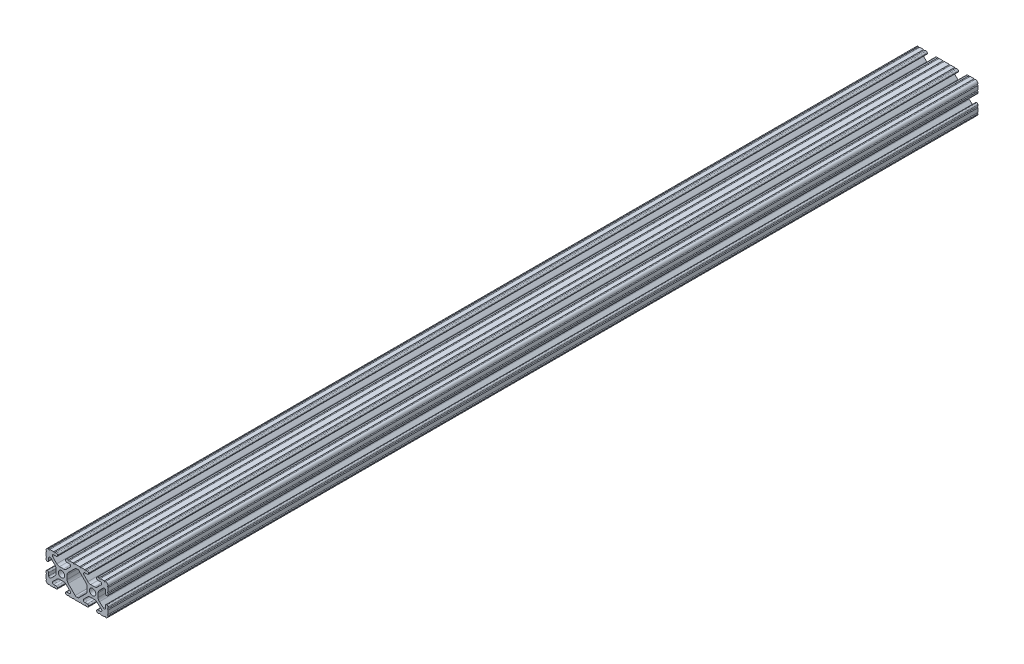
from build123d import *

# Parameters (mm, degrees)
SKETCH1_R           = 2.6035
BOSS_EXTRUDE1_DEPTH = 355.6


with BuildPart() as part:
    # Sketch1 → Boss-Extrude1 (new body, symmetric)
    with BuildSketch(Plane.XY):
        with BuildLine():
            Line((18.01710265, 12.7), (16.98745015, 12.7))
            ThreePointArc((16.98745015, 12.7), (16.245730386, 12.392769614), (15.9385, 11.65104985))
            Line((15.9385, 11.65104985), (15.9385, 11.53922))
            ThreePointArc((15.9385, 11.53922), (16.245750844, 10.797450844), (16.98752, 10.4902))
            Line((16.98752, 10.4902), (19.116384363, 10.4902))
            ThreePointArc((19.116384363, 10.4902), (20.052502933, 9.869096983), (19.844087081, 8.765172272))
            Line((19.844087081, 8.765172272), (16.618993479, 5.455112286))
            ThreePointArc((16.618993479, 5.455112286), (15.578994274, 4.745442459), (14.344932584, 4.4958))
            Line((14.344932584, 4.4958), (11.083317835, 4.4958))
            ThreePointArc((11.083317835, 4.4958), (9.854330953, 4.743306833), (8.816955189, 5.447238587))
            Line((8.816955189, 5.447238587), (5.564154119, 8.762652677))
            ThreePointArc((5.564154119, 8.762652677), (5.352591412, 9.867473037), (6.289393385, 10.4902))
            Line((6.289393385, 10.4902), (8.41248, 10.4902))
            ThreePointArc((8.41248, 10.4902), (9.154249156, 10.797450844), (9.4615, 11.53922))
            Line((9.4615, 11.53922), (9.4615, 11.65104985))
            ThreePointArc((9.4615, 11.65104985), (9.154269614, 12.392769614), (8.41254985, 12.7))
            Line((8.41254985, 12.7), (7.38288465, 12.7))
            ThreePointArc((7.38288465, 12.7), (6.87488465, 12.192), (6.36688465, 12.7))
            Line((6.36688465, 12.7), (3.14958095, 12.7))
            ThreePointArc((3.14958095, 12.7), (2.64158095, 12.192), (2.13358095, 12.7))
            Line((2.13358095, 12.7), (-2.13358095, 12.7))
            ThreePointArc((-2.13358095, 12.7), (-2.64158095, 12.192), (-3.14958095, 12.7))
            Line((-3.14958095, 12.7), (-6.36689735, 12.7))
            ThreePointArc((-6.36689735, 12.7), (-6.87489735, 12.192), (-7.38289735, 12.7))
            Line((-7.38289735, 12.7), (-8.41254985, 12.7))
            ThreePointArc((-8.41254985, 12.7), (-9.154269614, 12.392769614), (-9.4615, 11.65104985))
            Line((-9.4615, 11.65104985), (-9.4615, 11.53922))
            ThreePointArc((-9.4615, 11.53922), (-9.154249156, 10.797450844), (-8.41248, 10.4902))
            Line((-8.41248, 10.4902), (-6.283641037, 10.4902))
            ThreePointArc((-6.283641037, 10.4902), (-5.297291557, 9.829633109), (-5.532576693, 8.666071843))
            Line((-5.532576693, 8.666071843), (-8.809985098, 5.416263103))
            ThreePointArc((-8.809985098, 5.416263103), (-9.836720513, 4.734920264), (-11.045536121, 4.4958))
            Line((-11.045536121, 4.4958), (-14.354463879, 4.4958))
            ThreePointArc((-14.354463879, 4.4958), (-15.563279487, 4.734920264), (-16.590014902, 5.416263103))
            Line((-16.590014902, 5.416263103), (-19.867423307, 8.666071843))
            ThreePointArc((-19.867423307, 8.666071843), (-20.102708443, 9.829633109), (-19.116358963, 10.4902))
            Line((-19.116358963, 10.4902), (-16.98752, 10.4902))
            ThreePointArc((-16.98752, 10.4902), (-16.245750844, 10.797450844), (-15.9385, 11.53922))
            Line((-15.9385, 11.53922), (-15.9385, 11.65104985))
            ThreePointArc((-15.9385, 11.65104985), (-16.245730386, 12.392769614), (-16.98745015, 12.7))
            Line((-16.98745015, 12.7), (-18.01711535, 12.7))
            ThreePointArc((-18.01711535, 12.7), (-18.52511535, 12.192), (-19.03311535, 12.7))
            Line((-19.03311535, 12.7), (-22.2504, 12.7))
            ThreePointArc((-22.2504, 12.7), (-22.758323491, 12.192000006), (-23.266399977, 12.699846982))
            ThreePointArc((-23.266399977, 12.699846982), (-24.782522516, 12.082522516), (-25.399846982, 10.566399977))
            ThreePointArc((-25.399846982, 10.566399977), (-24.892000006, 10.058323491), (-25.4, 9.5504))
            Line((-25.4, 9.5504), (-25.4, 6.3330836))
            ThreePointArc((-25.4, 6.3330836), (-24.892, 5.8250836), (-25.4, 5.3170836))
            Line((-25.4, 5.3170836), (-25.4, 4.237520184))
            ThreePointArc((-25.4, 4.237520184), (-25.107393763, 3.531106237), (-24.400979816, 3.2385))
            Line((-24.400979816, 3.2385), (-24.23922, 3.2385))
            ThreePointArc((-24.23922, 3.2385), (-23.497450844, 3.545750844), (-23.1902, 4.28752))
            Line((-23.1902, 4.28752), (-23.1902, 6.334741132))
            ThreePointArc((-23.1902, 6.334741132), (-22.556026952, 7.286023527), (-21.434002553, 7.066535717))
            Line((-21.434002553, 7.066535717), (-18.147950853, 3.808156468))
            ThreePointArc((-18.147950853, 3.808156468), (-17.452759693, 2.774838327), (-17.208501877, 1.553619571))
            Line((-17.208501877, 1.553619571), (-17.208501877, -1.695179196))
            ThreePointArc((-17.208501877, -1.695179196), (-17.450738657, -2.911536421), (-18.140486065, -3.942289578))
            Line((-18.140486065, -3.942289578), (-21.431579576, -7.227386226))
            ThreePointArc((-21.431579576, -7.227386226), (-22.55444896, -7.449940594), (-23.1902, -6.498002195))
            Line((-23.1902, -6.498002195), (-23.1902, -4.28752))
            ThreePointArc((-23.1902, -4.28752), (-23.497450844, -3.545750844), (-24.23922, -3.2385))
            Line((-24.23922, -3.2385), (-24.35098, -3.2385))
            ThreePointArc((-24.35098, -3.2385), (-25.092749156, -3.545750844), (-25.4, -4.28752))
            Line((-25.4, -4.28752), (-25.4, -5.3171344))
            ThreePointArc((-25.4, -5.3171344), (-24.892, -5.8251344), (-25.4, -6.3331344))
            Line((-25.4, -6.3331344), (-25.4, -9.5504))
            ThreePointArc((-25.4, -9.5504), (-24.892000006, -10.058323491), (-25.399846982, -10.566399977))
            ThreePointArc((-25.399846982, -10.566399977), (-24.782522516, -12.082522516), (-23.266399977, -12.699846982))
            ThreePointArc((-23.266399977, -12.699846982), (-22.758323491, -12.192000006), (-22.2504, -12.7))
            Line((-22.2504, -12.7), (-19.03308995, -12.7))
            ThreePointArc((-19.03308995, -12.7), (-18.52508995, -12.192), (-18.01708995, -12.7))
            Line((-18.01708995, -12.7), (-16.9874692, -12.7))
            ThreePointArc((-16.9874692, -12.7), (-16.245700044, -12.392749156), (-15.9384492, -11.65098))
            Line((-15.9384492, -11.65098), (-15.9384492, -11.53922))
            ThreePointArc((-15.9384492, -11.53922), (-16.245700044, -10.797450844), (-16.9874692, -10.4902))
            Line((-16.9874692, -10.4902), (-19.116358963, -10.4902))
            ThreePointArc((-19.116358963, -10.4902), (-20.055197748, -9.862578342), (-19.834124023, -8.755124678))
            Line((-19.834124023, -8.755124678), (-16.49660751, -5.423689618))
            ThreePointArc((-16.49660751, -5.423689618), (-15.467274017, -4.736928798), (-14.253591699, -4.4958))
            Line((-14.253591699, -4.4958), (-11.146408301, -4.4958))
            ThreePointArc((-11.146408301, -4.4958), (-9.932725983, -4.736928798), (-8.90339249, -5.423689618))
            Line((-8.90339249, -5.423689618), (-5.565875977, -8.755124678))
            ThreePointArc((-5.565875977, -8.755124678), (-5.344802252, -9.862578342), (-6.283641037, -10.4902))
            Line((-6.283641037, -10.4902), (-8.4125308, -10.4902))
            ThreePointArc((-8.4125308, -10.4902), (-9.154299956, -10.797450844), (-9.4615508, -11.53922))
            Line((-9.4615508, -11.53922), (-9.4615508, -11.65098))
            ThreePointArc((-9.4615508, -11.65098), (-9.154299956, -12.392749156), (-8.4125308, -12.7))
            Line((-8.4125308, -12.7), (-7.38287195, -12.7))
            ThreePointArc((-7.38287195, -12.7), (-6.87487195, -12.192), (-6.36687195, -12.7))
            Line((-6.36687195, -12.7), (-3.14960635, -12.7))
            ThreePointArc((-3.14960635, -12.7), (-2.64160635, -12.192), (-2.13360635, -12.7))
            Line((-2.13360635, -12.7), (2.13360635, -12.7))
            ThreePointArc((2.13360635, -12.7), (2.64159365, -12.1920127), (3.14958095, -12.7))
            Line((3.14958095, -12.7), (6.36691005, -12.7))
            ThreePointArc((6.36691005, -12.7), (6.87491005, -12.192), (7.38291005, -12.7))
            Line((7.38291005, -12.7), (8.4125308, -12.7))
            ThreePointArc((8.4125308, -12.7), (9.154299956, -12.392749156), (9.4615508, -11.65098))
            Line((9.4615508, -11.65098), (9.4615508, -11.53922))
            ThreePointArc((9.4615508, -11.53922), (9.154299956, -10.797450844), (8.4125308, -10.4902))
            Line((8.4125308, -10.4902), (6.289393385, -10.4902))
            ThreePointArc((6.289393385, -10.4902), (5.231590322, -9.783049717), (5.480677245, -8.535265862))
            Line((5.480677245, -8.535265862), (8.597933595, -5.423689618))
            ThreePointArc((8.597933595, -5.423689618), (9.627267088, -4.736928798), (10.840949406, -4.4958))
            Line((10.840949406, -4.4958), (14.102564155, -4.4958))
            ThreePointArc((14.102564155, -4.4958), (15.215927525, -4.697410182), (16.187895372, -5.276636531))
            Line((16.187895372, -5.276636531), (19.868247549, -8.482246082))
            ThreePointArc((19.868247549, -8.482246082), (20.188435806, -9.746879864), (19.116384363, -10.4902))
            Line((19.116384363, -10.4902), (16.9874692, -10.4902))
            ThreePointArc((16.9874692, -10.4902), (16.245700044, -10.797450844), (15.9384492, -11.53922))
            Line((15.9384492, -11.53922), (15.9384492, -11.65098))
            ThreePointArc((15.9384492, -11.65098), (16.245700044, -12.392749156), (16.9874692, -12.7))
            Line((16.9874692, -12.7), (18.01710265, -12.7))
            ThreePointArc((18.01710265, -12.7), (18.52510265, -12.192), (19.03310265, -12.7))
            Line((19.03310265, -12.7), (22.2504, -12.7))
            ThreePointArc((22.2504, -12.7), (22.758323491, -12.192000006), (23.266399977, -12.699846982))
            ThreePointArc((23.266399977, -12.699846982), (24.782522516, -12.082522516), (25.399846982, -10.566399977))
            ThreePointArc((25.399846982, -10.566399977), (24.892000006, -10.058323492), (25.4, -9.550400001))
            Line((25.4, -9.550400001), (25.4, -6.333083592))
            ThreePointArc((25.4, -6.333083592), (24.892000001, -5.825083593), (25.4, -5.317083593))
            Line((25.4, -5.317083593), (25.4, -4.237520184))
            ThreePointArc((25.4, -4.237520184), (25.107393763, -3.531106237), (24.400979816, -3.2385))
            Line((24.400979816, -3.2385), (24.189220184, -3.2385))
            ThreePointArc((24.189220184, -3.2385), (23.482806237, -3.531106237), (23.1902, -4.237520184))
            Line((23.1902, -4.237520184), (23.1902, -6.155876159))
            ThreePointArc((23.1902, -6.155876159), (22.62232736, -7.038258539), (21.583974541, -6.886926384))
            Line((21.583974541, -6.886926384), (18.29817066, -4.024970844))
            ThreePointArc((18.29817066, -4.024970844), (17.493730985, -2.946044689), (17.208501877, -1.630807374))
            Line((17.208501877, -1.630807374), (17.208501877, 1.630807374))
            ThreePointArc((17.208501877, 1.630807374), (17.442348332, 2.82673414), (18.109440981, 3.846495088))
            Line((18.109440981, 3.846495088), (21.526346532, 7.353420386))
            ThreePointArc((21.526346532, 7.353420386), (22.585896263, 7.574939077), (23.1902, 6.676867167))
            Line((23.1902, 6.676867167), (23.1902, 4.237520184))
            ThreePointArc((23.1902, 4.237520184), (23.482806237, 3.531106237), (24.189220184, 3.2385))
            Line((24.189220184, 3.2385), (24.400979816, 3.2385))
            ThreePointArc((24.400979816, 3.2385), (25.107393763, 3.531106237), (25.4, 4.237520184))
            Line((25.4, 4.237520184), (25.4, 5.3170836))
            ThreePointArc((25.4, 5.3170836), (24.891949193, 5.825134407), (25.4, 6.333185215))
            Line((25.4, 6.333185215), (25.4, 9.550400015))
            ThreePointArc((25.4, 9.550400015), (24.892000013, 10.058323498), (25.399846982, 10.566399977))
            ThreePointArc((25.399846982, 10.566399977), (24.782522516, 12.082522516), (23.266399977, 12.699846982))
            ThreePointArc((23.266399977, 12.699846982), (22.758323491, 12.192000006), (22.2504, 12.7))
            Line((22.2504, 12.7), (19.03310265, 12.7))
            ThreePointArc((19.03310265, 12.7), (18.52510265, 12.192), (18.01710265, 12.7))
        make_face()
        with Locations((-12.7, 0)):
            Circle(SKETCH1_R, mode=Mode.SUBTRACT)
        with Locations((12.7, 0)):
            Circle(SKETCH1_R, mode=Mode.SUBTRACT)
        with BuildLine():
            Line((-7.259513935, -3.869413038), (-1.545748891, -9.572766749))
            ThreePointArc((-1.545748891, -9.572766749), (-1.035199478, -9.913400116), (-0.433213048, -10.033))
            Line((-0.433213048, -10.033), (0.433213048, -10.033))
            ThreePointArc((0.433213048, -10.033), (1.035199478, -9.913400116), (1.545748891, -9.572766749))
            Line((1.545748891, -9.572766749), (7.259513935, -3.869413038))
            ThreePointArc((7.259513935, -3.869413038), (7.949261343, -2.838659881), (8.191498123, -1.622302656))
            Line((8.191498123, -1.622302656), (8.191498123, 1.622302656))
            ThreePointArc((8.191498123, 1.622302656), (7.955573352, 2.823327967), (7.282860769, 3.845864069))
            Line((7.282860769, 3.845864069), (1.675572808, 9.561086461))
            ThreePointArc((1.675572808, 9.561086461), (1.161034429, 9.910236611), (0.551456936, 10.033))
            Line((0.551456936, 10.033), (-0.395199982, 10.033))
            ThreePointArc((-0.395199982, 10.033), (-0.994772524, 9.914396349), (-1.50403329, 9.576450301))
            Line((-1.50403329, 9.576450301), (-7.252049147, 3.876839553))
            ThreePointArc((-7.252049147, 3.876839553), (-7.947240307, 2.843521412), (-8.191498123, 1.622302656))
            Line((-8.191498123, 1.622302656), (-8.191498123, -1.622302656))
            ThreePointArc((-8.191498123, -1.622302656), (-7.949261343, -2.838659881), (-7.259513935, -3.869413038))
        make_face(mode=Mode.SUBTRACT)
    extrude(amount=BOSS_EXTRUDE1_DEPTH, both=True)


solid = part.part
